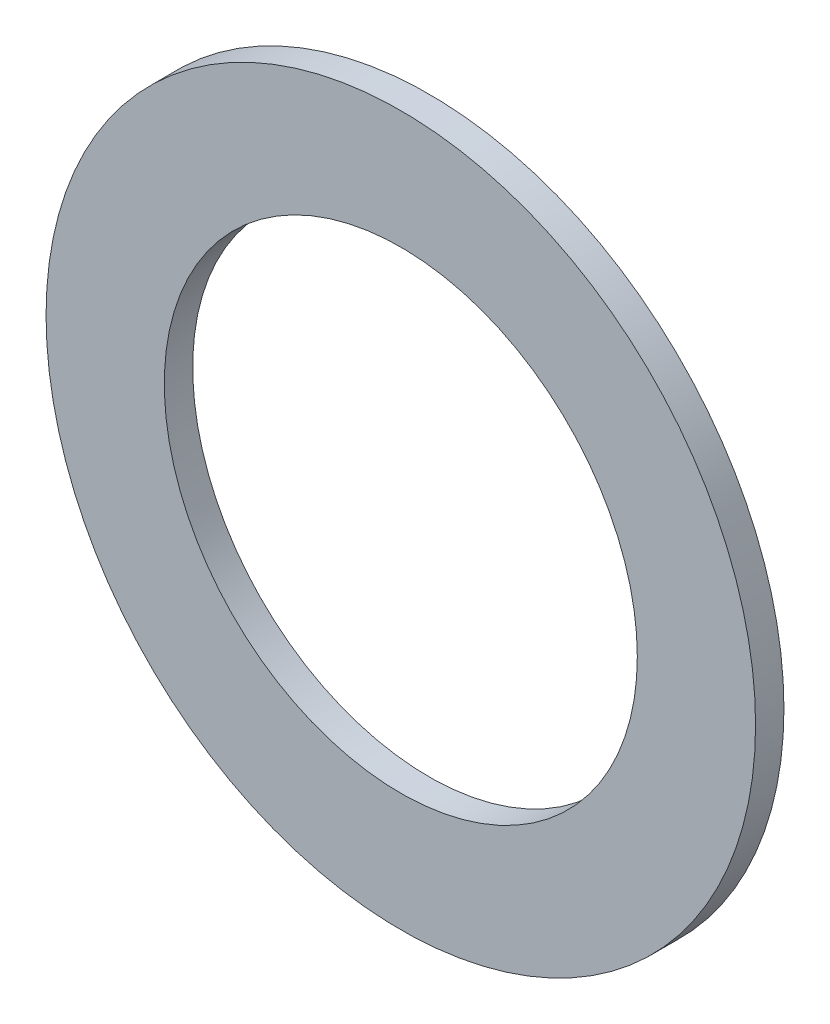
from build123d import *

# Parameters (mm, degrees)
SKETCH1_R           = 9.525
SKETCH1_R_2         = 6.35
BOSS_EXTRUDE1_DEPTH = 0.762


with BuildPart() as part:
    # Sketch1 → Boss-Extrude1 (new body)
    with BuildSketch(Plane.XY):
        Circle(SKETCH1_R)
        Circle(SKETCH1_R_2, mode=Mode.SUBTRACT)
    extrude(amount=BOSS_EXTRUDE1_DEPTH)


solid = part.part
